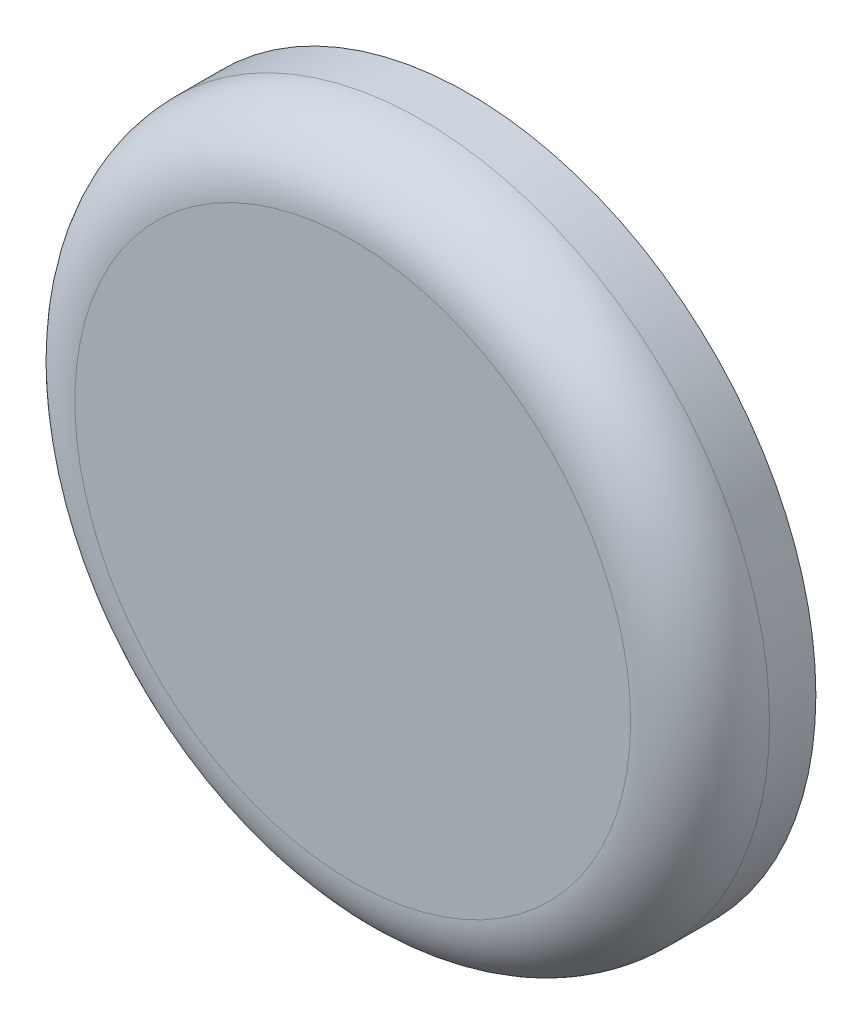
from build123d import *

# Parameters (mm, degrees)
SKETCH1_R      = 15
EXTRUDE1_DEPTH = 5
FILLET1_R      = 3


with BuildPart() as part:
    # Sketch1 → Extrude1 (new body)
    with BuildSketch(Plane.XY):
        Circle(SKETCH1_R)
    extrude(amount=EXTRUDE1_DEPTH)

    # Fillet1
    fillet1_edges = [part.edges().sort_by_distance(p)[0] for p in [
        (-15, 0, 5),
    ]]
    fillet(fillet1_edges, radius=FILLET1_R)


solid = part.part
